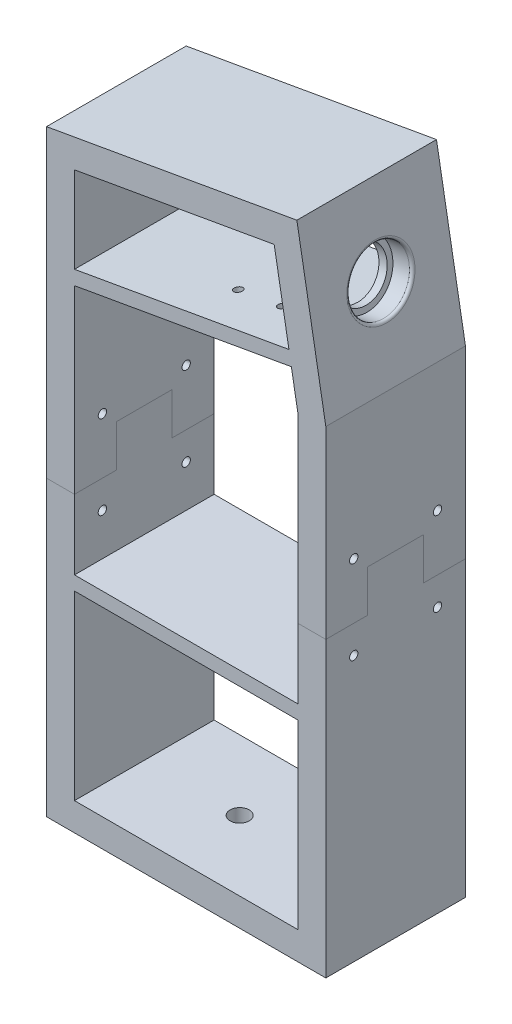
from build123d import *

# Parameters (mm, degrees)
BOSS_EXTRUDE1_DEPTH    = 50
SKETCH4_R              = 11.025
CUT_EXTRUDE1_DEPTH     = 7
SKETCH5_R              = 9
CUT_EXTRUDE2_DEPTH     = 7
BOSS_EXTRUDE2_DEPTH    = 50
SKETCH8_R              = 5
CUT_EXTRUDE3_DEPTH     = 10
CUT_EXTRUDE4_REACH     = 271.61
SKETCH9_R              = 1.485
SKETCH10_R             = 3.425
CUT_EXTRUDE5_DEPTH     = 10
SKETCH11_W             = 80
SKETCH11_H             = 5
BOSS_EXTRUDE3_DEPTH    = 50
FILLET1_R              = 1
SKETCH14_R             = 1.5
CUT_EXTRUDE6_DEPTH     = 256.567325306
SPLIT1_SURFACE_1_BACK  = 256.567
SPLIT1_SURFACE_1_DEPTH = 513.134
SPLIT1_SURFACE_2_BACK  = 256.567
SPLIT1_SURFACE_2_DEPTH = 513.134


with BuildPart() as part:
    # Sketch2 → Boss-Extrude1 (new body)
    with BuildSketch(Plane.XY):
        Polygon((-50, 214.01), (-50, 0), (50, 0), (50, 171.01), (39.631197958, 229.814398513), align=None)
        Polygon((-40, 205.619003688), (-40, 10), (40, 10), (40, 170.135113365), (31.519602204, 218.229839206), align=None, mode=Mode.SUBTRACT)
    extrude(amount=BOSS_EXTRUDE1_DEPTH)

    # Sketch4 → Cut-Extrude1 (cut)
    with BuildSketch(Plane(origin=(77.736747875, 13.707086043, 0), x_dir=(0, 0, -1), z_dir=(0.9848077530122079, 0.17364817766693136, 0))):
        with Locations(Location((-25, 190.058116105, 0), (0, 0, 90))):
            Circle(SKETCH4_R)
    extrude(amount=-CUT_EXTRUDE1_DEPTH, mode=Mode.SUBTRACT)

    # Sketch5 → Cut-Extrude2 (cut)
    with BuildSketch(Plane(origin=(70.843093604, 12.491548799, 0), x_dir=(0, 0, -1), z_dir=(0.9848077530122079, 0.17364817766693136, 0))):
        with Locations(Location((-25, 190.058116105, 0), (0, 0, 90))):
            Circle(SKETCH5_R)
    extrude(amount=-CUT_EXTRUDE2_DEPTH, mode=Mode.SUBTRACT)

    # Sketch7 → Boss-Extrude2 (add)
    with BuildSketch(Plane.XY.offset(50)):
        Polygon((36.795033842, 188.31137967), (37.66327473, 183.387340905), (-40, 169.69321016), (-40, 174.770343219), align=None)
    extrude(amount=-BOSS_EXTRUDE2_DEPTH)

    # Sketch8 → Cut-Extrude3 (cut)
    with BuildSketch(Plane.ZY.offset(50)):
        with Locations(Location((25, 193.163858422, 0), (0, 0, 270))):
            Circle(SKETCH8_R)
    extrude(amount=-CUT_EXTRUDE3_DEPTH, mode=Mode.SUBTRACT)

    # Sketch9 → Cut-Extrude4 (cut, up to next)
    with BuildSketch(Plane(origin=(125.115031087, 198.807445061, 0), x_dir=(-0.9848077530122079, -0.17364817766693152, 0), z_dir=(-0.17364817766693152, 0.9848077530122079, 0)), mode=Mode.PRIVATE) as cut_extrude4_sk1:
        with Locations((106.879323392, 15.4)):
            Circle(SKETCH9_R)
    cut_extrude4_tool1 = extrude(cut_extrude4_sk1.sketch, amount=CUT_EXTRUDE4_REACH, mode=Mode.PRIVATE) & part.part
    # Sketch9 → Cut-Extrude4 (cut, up to next)
    with BuildSketch(Plane(origin=(125.115031087, 198.807445061, 0), x_dir=(-0.9848077530122079, -0.17364817766693152, 0), z_dir=(-0.17364817766693152, 0.9848077530122079, 0)), mode=Mode.PRIVATE) as cut_extrude4_sk2:
        with Locations((106.879323392, 34.6)):
            Circle(SKETCH9_R)
    cut_extrude4_tool2 = extrude(cut_extrude4_sk2.sketch, amount=CUT_EXTRUDE4_REACH, mode=Mode.PRIVATE) & part.part
    # Sketch9 → Cut-Extrude4 (cut, up to next)
    with BuildSketch(Plane(origin=(125.115031087, 198.807445061, 0), x_dir=(-0.9848077530122079, -0.17364817766693152, 0), z_dir=(-0.17364817766693152, 0.9848077530122079, 0)), mode=Mode.PRIVATE) as cut_extrude4_sk3:
        with Locations(Location((122.879323392, 34.6, 0), (0, 0, 180))):
            Circle(SKETCH9_R)
    cut_extrude4_tool3 = extrude(cut_extrude4_sk3.sketch, amount=CUT_EXTRUDE4_REACH, mode=Mode.PRIVATE) & part.part
    # Sketch9 → Cut-Extrude4 (cut, up to next)
    with BuildSketch(Plane(origin=(125.115031087, 198.807445061, 0), x_dir=(-0.9848077530122079, -0.17364817766693152, 0), z_dir=(-0.17364817766693152, 0.9848077530122079, 0)), mode=Mode.PRIVATE) as cut_extrude4_sk4:
        with Locations(Location((122.879323392, 15.4, 0), (0, 0, 180))):
            Circle(SKETCH9_R)
    cut_extrude4_tool4 = extrude(cut_extrude4_sk4.sketch, amount=CUT_EXTRUDE4_REACH, mode=Mode.PRIVATE) & part.part
    add(cut_extrude4_tool1.solids().sort_by_distance((19.859445, 180.248045, 15.4))[0], mode=Mode.SUBTRACT)
    add(cut_extrude4_tool2.solids().sort_by_distance((19.859445, 180.248045, 34.6))[0], mode=Mode.SUBTRACT)
    add(cut_extrude4_tool3.solids().sort_by_distance((4.102521, 177.469674, 34.6))[0], mode=Mode.SUBTRACT)
    add(cut_extrude4_tool4.solids().sort_by_distance((4.102521, 177.469674, 15.4))[0], mode=Mode.SUBTRACT)

    # Sketch10 → Cut-Extrude5 (cut)
    with BuildSketch(Plane(origin=(0, 10, 0), x_dir=(1, 0, 0), z_dir=(0, 1, 0))):
        with Locations(Location((-5.851287133, -25, 0), (0, 0, 180))):
            Circle(SKETCH10_R)
        with Locations(Location((24.130974018, -25, 0), (0, 0, 180))):
            Circle(SKETCH10_R)
    extrude(amount=-CUT_EXTRUDE5_DEPTH, mode=Mode.SUBTRACT)

    # Sketch11 → Boss-Extrude3 (add)
    with BuildSketch(Plane.XY.offset(50)):
        with Locations((0, 77.5)):
            Rectangle(SKETCH11_W, SKETCH11_H)
    extrude(amount=-BOSS_EXTRUDE3_DEPTH)

    # Fillet1
    fillet1_edges = [part.edges().sort_by_distance(p)[0] for p in [
        (46.647973521, 190.020286829, 25),
    ]]
    fillet(fillet1_edges, radius=FILLET1_R)

    # Sketch14 → Cut-Extrude6 (cut, through all)
    with BuildSketch(Plane.ZY.offset(50)):
        with Locations(Location((40, 125, 0), (0, 0, 270))):
            Circle(SKETCH14_R)
        with Locations(Location((40, 95, 0), (0, 0, 270))):
            Circle(SKETCH14_R)
        with Locations((10, 95)):
            Circle(SKETCH14_R)
        with Locations((10, 125)):
            Circle(SKETCH14_R)
    extrude(amount=-CUT_EXTRUDE6_DEPTH, mode=Mode.SUBTRACT)


with BuildPart() as body_2:
    # Split1: the piece behind the surface
    add(part.part)
    # Split1 surface: a surface, the sketch's curves swept straight by 513.134 mm
    with BuildLine(Plane.ZY.offset(50).offset(-SPLIT1_SURFACE_1_BACK), mode=Mode.PRIVATE) as split1_surface_1_path:
        Line((0, 105), (15, 105))
        Line((15, 105), (15, 120))
        Line((15, 120), (35, 120))
        Line((35, 120), (35, 105))
        Line((35, 105), (50, 105))
    split1_surface_1 = Shell.extrude(split1_surface_1_path.wire(), (-1 * SPLIT1_SURFACE_1_DEPTH, 0 * SPLIT1_SURFACE_1_DEPTH, 0 * SPLIT1_SURFACE_1_DEPTH))
    split(bisect_by=split1_surface_1, keep=Keep.BOTTOM)


with BuildPart() as part_1:
    add(part.part)

    # Split1: split by a surface, the side it looks to stays
    # Split1 surface: a surface, the sketch's curves swept straight by 513.134 mm
    with BuildLine(Plane.ZY.offset(50).offset(-SPLIT1_SURFACE_2_BACK), mode=Mode.PRIVATE) as split1_surface_2_path:
        Line((0, 105), (15, 105))
        Line((15, 105), (15, 120))
        Line((15, 120), (35, 120))
        Line((35, 120), (35, 105))
        Line((35, 105), (50, 105))
    split1_surface_2 = Shell.extrude(split1_surface_2_path.wire(), (-1 * SPLIT1_SURFACE_2_DEPTH, 0 * SPLIT1_SURFACE_2_DEPTH, 0 * SPLIT1_SURFACE_2_DEPTH))
    split(bisect_by=split1_surface_2, keep=Keep.TOP)


solid = Compound([body_2.part, part_1.part])
